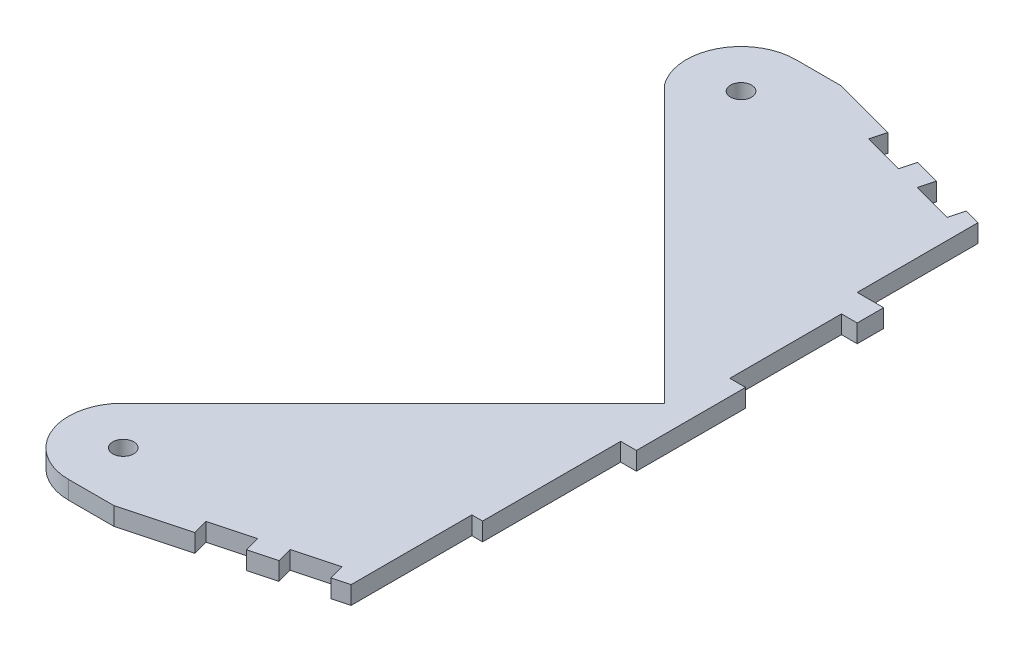
from build123d import *

# Parameters (mm, degrees)
SKETCH1_R           = 3.175
BOSS_EXTRUDE1_DEPTH = 5.461
SKETCH3_W           = 4.7625
SKETCH3_H           = 33.783
SKETCH3_H_2         = 46.289475607
CUT_EXTRUDE2_DEPTH  = 10


with BuildPart() as part:
    # Sketch1 → Boss-Extrude1 (new body)
    with BuildSketch(Plane(origin=(0, 0, 0), x_dir=(1, 0, 0), z_dir=(0, 1, 0))):
        with BuildLine():
            Line((0, 0), (-83.629476528, 83.629476528))
            ThreePointArc((-83.629476528, 83.629476528), (-85.081850373, 100.91197572), (-70.310188895, 110))
            Line((-70.310188895, 110), (-56.601944845, 110))
            Line((-56.601944845, 110), (0, 94.833554589))
            Line((0, 94.833554589), (0, 58.293))
            Line((0, 58.293), (8, 58.293))
            Line((8, 58.293), (8, -58.293))
            Line((8, -58.293), (0, -58.293))
            Line((0, -58.293), (0, -94.833554589))
            Line((0, -94.833554589), (-56.601944845, -110))
            Line((-56.601944845, -110), (-70.310188895, -110))
            ThreePointArc((-70.310188895, -110), (-85.081850373, -100.91197572), (-83.629476528, -83.629476528))
            Line((-83.629476528, -83.629476528), (0, 0))
        make_face()
        with Locations((-70.310188895, 93.451069294)):
            Circle(SKETCH1_R, mode=Mode.SUBTRACT)
        with Locations((-70.310188895, -93.451069294)):
            Circle(SKETCH1_R, mode=Mode.SUBTRACT)
    extrude(amount=BOSS_EXTRUDE1_DEPTH)

    # Sketch3 → Cut-Extrude2 (cut)
    with BuildSketch(Plane(origin=(0, 0, 0), x_dir=(1, 0, 0), z_dir=(0, 1, 0))):
        Polygon((-4.829629131, 96.127649814), (-17.19282542, 99.440358276), (-18.425451123, 94.840136528), (-6.062254834, 91.527428067), align=None)
        Polygon((-24.920232031, 101.510910637), (-37.283428319, 104.823619098), (-38.516054022, 100.22339735), (-26.152857733, 96.910688889), align=None)
        with Locations((5.61875, 33.4015)):
            Rectangle(SKETCH3_W, SKETCH3_H)
        Polygon((-26.152857733, -96.910688889), (-38.516054022, -100.22339735), (-37.283428319, -104.823619098), (-24.920232031, -101.510910637), align=None)
        Polygon((-6.062254834, -91.527428067), (-18.425451123, -94.840136528), (-17.19282542, -99.440358276), (-4.829629131, -96.127649814), align=None)
        with Locations((5.61875, -39.654737804)):
            Rectangle(SKETCH3_W, SKETCH3_H_2)
    extrude(amount=CUT_EXTRUDE2_DEPTH, mode=Mode.SUBTRACT)


solid = part.part
